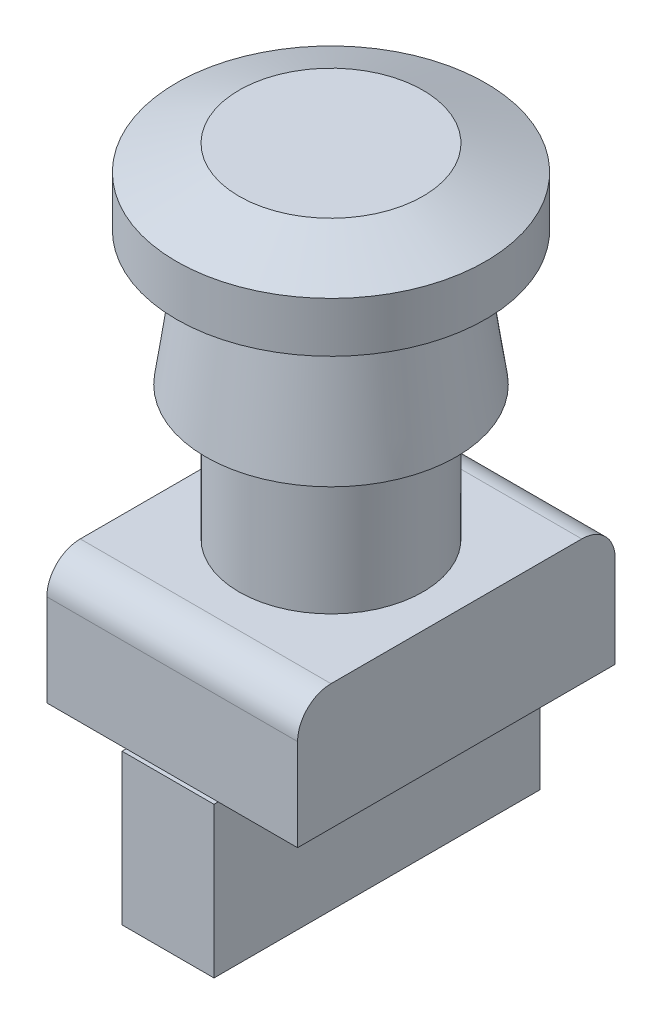
from build123d import *

# Parameters (mm, degrees)
SZKIC1_R                    = 15
DODANIE_WYCI_GNI_CIE1_DEPTH = 15
DODANIE_WYCI_GNI_CIE1_TAPER = 8
SZKIC1_3_R                  = 11
DODANIE_WYCI_GNI_CIE2_DEPTH = 16
DODANIE_WYCI_GNI_CIE3_START = -16
SZKIC1_4_W                  = 30
SZKIC1_4_H                  = 38
DODANIE_WYCI_GNI_CIE3_DEPTH = 15
DODANIE_WYCI_GNI_CIE4_START = -31
SZKIC1_5_W                  = 11
SZKIC1_5_H                  = 39
DODANIE_WYCI_GNI_CIE4_DEPTH = 18
ZAOKR_GLENIE1_R             = 4


with BuildPart() as part:
    # Szkic1 → Dodanie-wyci_gni_cie1 (new body)
    with BuildSketch(Plane(origin=(0, 0, 0), x_dir=(1, 0, 0), z_dir=(0, 1, 0))):
        Circle(SZKIC1_R)
    extrude(amount=DODANIE_WYCI_GNI_CIE1_DEPTH, taper=DODANIE_WYCI_GNI_CIE1_TAPER)

    # Szkic1_3 → Dodanie-wyci_gni_cie2 (add)
    with BuildSketch(Plane(origin=(0, 0, 0), x_dir=(1, 0, 0), z_dir=(0, 1, 0))):
        Circle(SZKIC1_3_R)
    extrude(amount=-DODANIE_WYCI_GNI_CIE2_DEPTH)

    # Szkic1_4 → Dodanie-wyci_gni_cie3 (add)
    with BuildSketch(Plane(origin=(0, 0, 0), x_dir=(1, 0, 0), z_dir=(0, 1, 0)).offset(DODANIE_WYCI_GNI_CIE3_START)):
        Rectangle(SZKIC1_4_W, SZKIC1_4_H)
    extrude(amount=-DODANIE_WYCI_GNI_CIE3_DEPTH)

    # Szkic1_5 → Dodanie-wyci_gni_cie4 (add)
    with BuildSketch(Plane(origin=(0, 0, 0), x_dir=(1, 0, 0), z_dir=(0, 1, 0)).offset(DODANIE_WYCI_GNI_CIE4_START)):
        Rectangle(SZKIC1_5_W, SZKIC1_5_H)
    extrude(amount=-DODANIE_WYCI_GNI_CIE4_DEPTH)

    # Szkic2 → Obr_t1 (revolve)
    with BuildSketch(Plane(origin=(0, 0, 0), x_dir=(0, 0, -1), z_dir=(1, 0, 0))):
        Polygon((0, 15), (0, 25), (11, 25), (18.5, 22), (18.5, 16), (12, 16), (12, 15), align=None)
    revolve(axis=Axis((0, 34.075059211, 0), (0, -1, 0)))

    # Zaokr_glenie1
    zaokr_glenie1_edges = [part.edges().sort_by_distance(p)[0] for p in [
        (0, -16, -19),
        (0, -16, 19),
    ]]
    fillet(zaokr_glenie1_edges, radius=ZAOKR_GLENIE1_R)


solid = part.part
